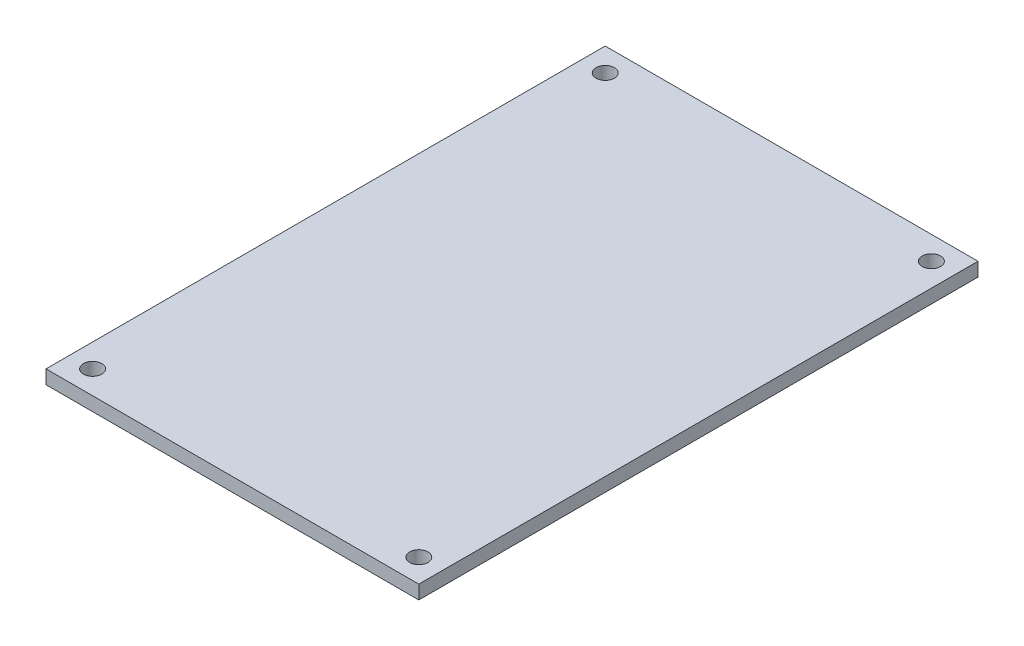
from build123d import *

# Parameters (mm, degrees)
SKETCH1_W           = 40.64
SKETCH1_H           = 60.96
SKETCH1_R           = 1
SKETCH1_R_2         = 0.5
BOSS_EXTRUDE1_DEPTH = 1.5
SKETCH1_5_R         = 0.5
CUT_EXTRUDE1_DEPTH  = 0.75


with BuildPart() as part:
    # Sketch1 → Boss-Extrude1 (new body)
    with BuildSketch(Plane(origin=(0, 0, 0), x_dir=(1, 0, 0), z_dir=(0, 1, 0))):
        with Locations((20.32, 30.48)):
            Rectangle(SKETCH1_W, SKETCH1_H)
        with Locations(Location((38.1, 58.42, 0), (0, 0, 270))):  # turned: the seam where the file's is
            Circle(SKETCH1_R, mode=Mode.SUBTRACT)
        with Locations((38.1, 50.8)):
            Circle(SKETCH1_R_2, mode=Mode.SUBTRACT)
        with Locations(Location((38.1, 2.54, 0), (0, 0, 270))):  # turned: the seam where the file's is
            Circle(SKETCH1_R, mode=Mode.SUBTRACT)
        with Locations(Location((2.54, 58.42, 0), (0, 0, 270))):  # turned: the seam where the file's is
            Circle(SKETCH1_R, mode=Mode.SUBTRACT)
        with Locations((2.54, 10.16)):
            Circle(SKETCH1_R_2, mode=Mode.SUBTRACT)
        with Locations(Location((2.54, 2.54, 0), (0, 0, 270))):  # turned: the seam where the file's is
            Circle(SKETCH1_R, mode=Mode.SUBTRACT)
        with Locations((2.54, 50.8)):
            Circle(SKETCH1_R_2, mode=Mode.SUBTRACT)
        with Locations((38.1, 10.16)):
            Circle(SKETCH1_R_2, mode=Mode.SUBTRACT)
        with Locations((2.54, 10.16)):
            Circle(SKETCH1_R_2)
        with Locations((38.1, 10.16)):
            Circle(SKETCH1_R_2)
        with Locations((38.1, 50.8)):
            Circle(SKETCH1_R_2)
        with Locations((2.54, 50.8)):
            Circle(SKETCH1_R_2)
    extrude(amount=BOSS_EXTRUDE1_DEPTH)

    # Sketch1_5 → Cut-Extrude1 (cut)
    with BuildSketch(Plane(origin=(0, 0, 0), x_dir=(1, 0, 0), z_dir=(0, 1, 0))):
        with Locations(Location((2.54, 50.8, 0), (0, 0, 270))):  # turned: the seam where the file's is
            Circle(SKETCH1_5_R)
        with Locations(Location((38.1, 50.8, 0), (0, 0, 270))):  # turned: the seam where the file's is
            Circle(SKETCH1_5_R)
        with Locations(Location((38.1, 10.16, 0), (0, 0, 270))):  # turned: the seam where the file's is
            Circle(SKETCH1_5_R)
        with Locations(Location((2.54, 10.16, 0), (0, 0, 270))):  # turned: the seam where the file's is
            Circle(SKETCH1_5_R)
    extrude(amount=CUT_EXTRUDE1_DEPTH, mode=Mode.SUBTRACT)


solid = part.part
